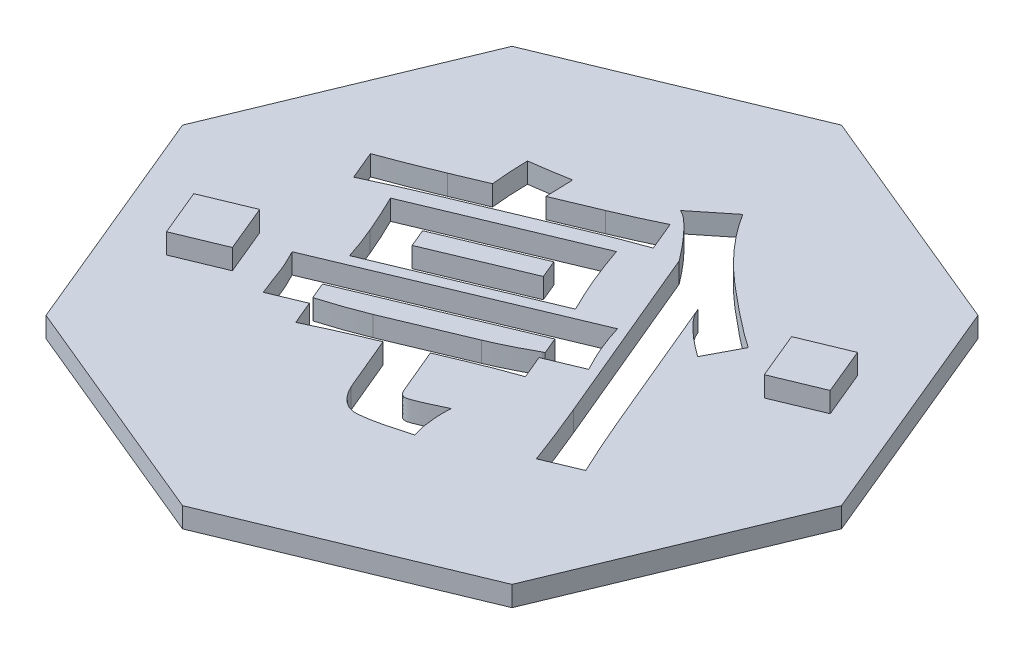
from build123d import *

# Parameters (mm, degrees)
EXTRUDE_1_DEPTH     = 2
CUT_EXTRUDE_1_DEPTH = 2
EXTRUDE_2_DEPTH     = 2
CUT_EXTRUDE_2_DEPTH = 2


with BuildPart() as part:
    # 草图1 → 凸台-拉伸1 (new body)
    with BuildSketch(Plane(origin=(0, 0, 0), x_dir=(1, 0, 0), z_dir=(0, 1, 0))):
        Polygon((32.664074122, 0), (23.096988313, 23.096988313), (0, 32.664074122), (-23.096988313, 23.096988313), (-32.664074122, 0), (-23.096988313, -23.096988313), (0, -32.664074122), (23.096988313, -23.096988313), align=None)
    extrude(amount=EXTRUDE_1_DEPTH)

    # 草图2 → 切除-拉伸1 (cut)
    with BuildSketch(Plane(origin=(0, 0, 0), x_dir=(-1, 0, 0), z_dir=(0, -1, 0))):
        with BuildLine():
            add(Edge.make_bspline(
                [(16.093868601, 4.045594361), (15.797609581, 3.441508397), (15.191422794, 2.205465258), (14.650057175, 0.939674375), (14.37327081, 0.292507942)],
                knots=[0, 0, 0, 0, 0.977451264, 2, 2, 2, 2], degree=3))
            add(Edge.make_bspline(
                [(14.37327081, 0.292507942), (14.251067666, -0.005151179), (14.015944237, -0.577858483), (13.691365396, -1.409985886), (13.414727332, -2.185125978), (13.254412551, -2.685633489), (13.177689264, -2.925165873)],
                knots=[0, 0, 0, 0, 1.124444144, 2.163472675, 3.121076593, 4, 4, 4, 4], degree=3))
            Line((13.177689264, -2.925165873), (-2.614383511, 3.681721717))
            add(Edge.make_bspline(
                [(-2.614383511, 3.681721717), (-2.335416626, 4.24418675), (-1.785453017, 5.353047036), (-1.296073162, 6.489936185), (-1.05492932, 7.050142769)],
                knots=[0, 0, 0, 0, 1.014492161, 2, 2, 2, 2], degree=3))
            add(Edge.make_bspline(
                [(-1.05492932, 7.050142769), (-0.823492736, 7.621996478), (-0.341990134, 8.811735129), (0.081735825, 10.023274771), (0.301795826, 10.652481951)],
                knots=[0, 0, 0, 0, 0.961309795, 2, 2, 2, 2], degree=3))
            Line((0.301795826, 10.652481951), (16.093868601, 4.045594361))
        make_face()
        Polygon((10.952867951, 1.056640495), (11.696207782, 2.834418273), (2.526617139, 6.670675583), (1.783277308, 4.892897805), align=None, mode=Mode.SUBTRACT)
        with BuildLine():
            add(Edge.make_bspline(
                [(0.650073929, 17.352936791), (0.528625853, 17.291965561), (0.258232802, 17.156218682), (-0.145672538, 16.852090468), (-0.602649888, 16.456694691), (-1.103720534, 15.952631829), (-1.659283349, 15.353785572), (-2.26797484, 14.656754371), (-2.922153811, 13.853633684), (-3.367674816, 13.278574375), (-3.602037832, 12.976068695)],
                knots=[0, 0, 0, 0, 0.529975625, 1.179942343, 1.967013512, 2.890804666, 3.954079264, 5.158222661, 6.505104134, 8, 8, 8, 8], degree=3))
            Line((-3.602037832, 12.976068695), (-11.144597936, -5.056419934))
            add(Edge.make_bspline(
                [(-11.144597936, -5.056419934), (-11.560749256, -6.066170811), (-12.386726324, -8.070324178), (-13.147761295, -10.1000242), (-13.525364668, -11.107102195)],
                knots=[0, 0, 0, 0, 1.00765829, 2, 2, 2, 2], degree=3))
            Line((-13.525364668, -11.107102195), (-16.97175843, -9.662007978))
            add(Edge.make_bspline(
                [(-16.97175843, -9.662007978), (-16.515344789, -8.683913243), (-15.618447079, -6.761860855), (-14.789953789, -4.809355654), (-14.383064473, -3.850442026)],
                knots=[0, 0, 0, 0, 1.017760744, 2, 2, 2, 2], degree=3))
            Line((-14.383064473, -3.850442026), (-8.711849398, 9.711611255))
            add(Edge.make_bspline(
                [(-8.711849398, 9.711611255), (-8.768635747, 9.576192979), (-8.891538705, 9.283106576), (-9.178837093, 8.853286544), (-9.548667996, 8.392082955), (-10.013151245, 7.902599454), (-10.562602084, 7.379860625), (-11.206377612, 6.828866385), (-11.939922648, 6.246398661), (-12.468705344, 5.859602102), (-12.745637572, 5.657030359)],
                knots=[0, 0, 0, 0, 0.608207383, 1.316346051, 2.135024255, 3.060935765, 4.113768122, 5.281360114, 6.576203409, 8, 8, 8, 8], degree=3))
            add(Edge.make_bspline(
                [(-12.745637572, 5.657030359), (-12.913552134, 5.979401586), (-13.233274988, 6.593222373), (-13.689379302, 7.462839994), (-14.095129779, 8.237335638), (-14.354865647, 8.717279379), (-14.476631724, 8.942280521)],
                knots=[0, 0, 0, 0, 1.17459343, 2.236520518, 3.173267898, 4, 4, 4, 4], degree=3))
            add(Edge.make_bspline(
                [(-14.476631724, 8.942280521), (-14.300920384, 9.060830104), (-13.928660656, 9.311987686), (-13.351729699, 9.733032157), (-12.713104962, 10.202505378), (-12.02006005, 10.736966006), (-11.268687532, 11.326520979), (-10.46306757, 11.978655629), (-9.598624398, 12.685531184), (-8.693957949, 13.442254995), (-7.778781193, 14.224320346), (-6.910102452, 15.039635825), (-6.08985237, 15.859358557), (-5.315852532, 16.684801699), (-4.605667791, 17.528163283), (-3.945886234, 18.377839109), (-3.324704865, 19.227456213), (-2.957454615, 19.81628166), (-2.775527111, 20.107972529)],
                knots=[0, 0, 0, 0, 0.624797072, 1.323686839, 2.105215423, 2.961352331, 3.903497222, 4.920602144, 6.016748156, 7.195261844, 8.397523628, 9.564826044, 10.706169216, 11.815717331, 12.899427477, 13.954902417, 14.986904706, 16, 16, 16, 16], degree=3))
            Line((-2.775527111, 20.107972529), (0.650073929, 17.352936791))
        make_face()
        with BuildLine():
            add(Edge.make_bspline(
                [(6.986656125, -6.813404989), (7.301317032, -6.939957603), (7.959772221, -7.204779903), (9.005183632, -7.582525656), (10.150941485, -7.959878634), (10.949017228, -8.207737979), (11.363524221, -8.336471915)],
                knots=[0, 0, 0, 0, 0.877828429, 1.83693199, 2.876539196, 4, 4, 4, 4], degree=3))
            Line((11.363524221, -8.336471915), (10.115960868, -11.320227601))
            add(Edge.make_bspline(
                [(10.115960868, -11.320227601), (9.729954805, -11.135724727), (8.990723516, -10.782387539), (7.924823899, -10.289016756), (6.952344225, -9.849119608), (6.330415569, -9.584708546), (6.035389069, -9.459278933)],
                knots=[0, 0, 0, 0, 1.14461078, 2.192017644, 3.142341002, 4, 4, 4, 4], degree=3))
            Line((6.035389069, -9.459278933), (4.127656775, -8.658759115))
            Line((4.127656775, -8.658759115), (1.845655475, -14.111650603))
            add(Edge.make_bspline(
                [(1.845655475, -14.111650603), (1.755644329, -14.283543624), (1.583517145, -14.612252489), (1.280105734, -15.051731058), (0.959924509, -15.419999049), (0.616323836, -15.709665903), (0.259846681, -15.937396895), (-0.124946041, -16.078941435), (-0.527616305, -16.140417879), (-0.948021685, -16.131838856), (-1.388036152, -16.063565293), (-1.864272592, -15.995868595), (-2.373000907, -15.893260528), (-2.919005882, -15.774262108), (-3.501153746, -15.633120366), (-4.118232955, -15.472481361), (-4.769611799, -15.289704958), (-5.213664503, -15.157134974), (-5.442193777, -15.088908563)],
                knots=[0, 0, 0, 0, 1.12099087, 2.143656759, 3.080474238, 3.933513291, 4.734236404, 5.514002854, 6.28483668, 7.076356498, 7.935024684, 8.857428312, 9.857517109, 10.934394087, 12.088603092, 13.32058556, 14.621054139, 16, 16, 16, 16], degree=3))
            add(Edge.make_bspline(
                [(-5.442193777, -15.088908563), (-5.351871048, -14.776892277), (-5.168766904, -14.144366272), (-5.023450603, -13.145778745), (-4.943018512, -12.099305758), (-4.970629008, -11.384440946), (-4.984753881, -11.018733124)],
                knots=[0, 0, 0, 0, 0.945578486, 1.916896679, 2.934333924, 4, 4, 4, 4], degree=3))
            add(Edge.make_bspline(
                [(-4.984753881, -11.018733124), (-4.790847683, -11.110907326), (-4.42260794, -11.285951777), (-3.898581085, -11.528685049), (-3.433739183, -11.744604284), (-3.026727982, -11.925384347), (-2.6751308, -12.073315457), (-2.381740422, -12.186560583), (-2.146333985, -12.270874943), (-1.921608575, -12.343644017), (-1.681251188, -12.363075023), (-1.426685911, -12.279098104), (-1.217234804, -12.094046724), (-1.135377032, -11.922165451), (-1.091316584, -11.829649303)],
                knots=[0, 0, 0, 0, 1.75727236, 3.337167794, 4.726874983, 5.952299164, 6.982142917, 7.848648666, 8.525986127, 9.028603242, 9.781461031, 10.454180059, 11.167952948, 12, 12, 12, 12], degree=3))
            Line((-1.091316584, -11.829649303), (0.816415709, -7.276043066))
            Line((0.816415709, -7.276043066), (-1.813863693, -6.174028771))
            add(Edge.make_bspline(
                [(-1.813863693, -6.174028771), (-2.13587428, -6.041669541), (-2.790307403, -5.772671353), (-3.796809741, -5.373853668), (-4.849321953, -4.988445414), (-5.566741733, -4.733539559), (-5.930822757, -4.604178218)],
                knots=[0, 0, 0, 0, 0.948046538, 1.926747385, 2.947851791, 4, 4, 4, 4], degree=3))
            Line((-5.930822757, -4.604178218), (-4.683259404, -1.620422533))
            add(Edge.make_bspline(
                [(-4.683259404, -1.620422533), (-4.338036667, -1.813500775), (-3.656638491, -2.194597232), (-2.625617228, -2.715586575), (-1.614318872, -3.203477177), (-0.936462835, -3.494176659), (-0.602687605, -3.63731662)],
                knots=[0, 0, 0, 0, 1.042091168, 2.056872116, 3.043206934, 4, 4, 4, 4], degree=3))
            Line((-0.602687605, -3.63731662), (6.986656125, -6.813404989))
        make_face()
        with BuildLine():
            add(Edge.make_bspline(
                [(16.358975813, -5.43588712), (16.242836134, -5.656792271), (16.015225652, -6.08972207), (15.709843027, -6.743111047), (15.430403129, -7.378326322), (15.13058927, -8.204912883), (14.770924016, -9.196992014), (14.458702726, -9.969560292), (14.305694462, -10.348167822)],
                knots=[0, 0, 0, 0, 0.842857433, 1.65183156, 2.435688405, 3.185759508, 4.6208434, 6, 6, 6, 6], degree=3))
            Line((14.305694462, -10.348167822), (11.119209731, -9.017433579))
            Line((11.119209731, -9.017433579), (12.08607133, -6.704243196))
            Line((12.08607133, -6.704243196), (-4.15304498, 0.094977077))
            Line((-4.15304498, 0.094977077), (-5.119906578, -2.218213306))
            Line((-5.119906578, -2.218213306), (-8.436345824, -0.835497257))
            add(Edge.make_bspline(
                [(-8.436345824, -0.835497257), (-8.314627446, -0.598333908), (-8.082516959, -0.146075991), (-7.759338065, 0.49995068), (-7.486607848, 1.086373847), (-7.326603731, 1.458281441), (-7.251160639, 1.633638546)],
                knots=[0, 0, 0, 0, 1.167656215, 2.226658417, 3.163856695, 4, 4, 4, 4], degree=3))
            add(Edge.make_bspline(
                [(-7.251160639, 1.633638546), (-7.097580529, 2.02014236), (-6.778226528, 2.823837183), (-6.518095982, 3.648637011), (-6.383064473, 4.076783445)],
                knots=[0, 0, 0, 0, 0.961817353, 2, 2, 2, 2], degree=3))
            Line((-6.383064473, 4.076783445), (16.358975813, -5.43588712))
        make_face()
        with BuildLine():
            add(Edge.make_bspline(
                [(12.486331239, 14.020903003), (12.478695551, 13.69165781), (12.463781285, 13.048565689), (12.42463406, 12.10540087), (12.357267249, 11.20575478), (12.293820878, 10.621141189), (12.262809471, 10.335392932)],
                knots=[0, 0, 0, 0, 1.069883436, 2.089730157, 3.066295606, 4, 4, 4, 4], degree=3))
            Line((12.262809471, 10.335392932), (15.423303299, 9.009856869))
            add(Edge.make_bspline(
                [(15.423303299, 9.009856869), (15.913396476, 8.808210949), (16.869463055, 8.414843048), (18.270747575, 7.850970888), (19.608573249, 7.342579524), (20.4791056, 7.02335168), (20.90218569, 6.868206447)],
                knots=[0, 0, 0, 0, 1.080965888, 2.10873239, 3.080840972, 4, 4, 4, 4], degree=3))
            Line((20.90218569, 6.868206447), (19.711802324, 4.014405277))
            add(Edge.make_bspline(
                [(19.711802324, 4.014405277), (18.822004235, 4.432515769), (17.045637292, 5.267219356), (15.238706529, 6.033513952), (14.336883546, 6.415964732)],
                knots=[0, 0, 0, 0, 1.001817887, 2, 2, 2, 2], degree=3))
            Line((14.336883546, 6.415964732), (3.27515515, 11.047543679))
            add(Edge.make_bspline(
                [(3.27515515, 11.047543679), (2.929136533, 11.190936111), (2.222237029, 11.483879999), (1.123725329, 11.909671499), (-0.030118119, 12.345181739), (-0.822404842, 12.632172958), (-1.226469281, 12.778537831)],
                knots=[0, 0, 0, 0, 0.931797729, 1.90361824, 2.93085004, 4, 4, 4, 4], degree=3))
            Line((-1.226469281, 12.778537831), (-0.036085915, 15.632339001))
            add(Edge.make_bspline(
                [(-0.036085915, 15.632339001), (0.696257069, 15.282370936), (2.148422597, 14.588418006), (3.628110045, 13.955276918), (4.361574904, 13.641435817)],
                knots=[0, 0, 0, 0, 1.00862191, 2, 2, 2, 2], degree=3))
            Line((4.361574904, 13.641435817), (8.530515774, 11.894847123))
            add(Edge.make_bspline(
                [(8.530515774, 11.894847123), (8.537587927, 12.090640434), (8.552482363, 12.502994494), (8.572988056, 13.152779971), (8.593917286, 13.866661865), (8.606900987, 14.363978916), (8.613686664, 14.623891957)],
                knots=[0, 0, 0, 0, 0.861087373, 1.813508701, 2.857273038, 4, 4, 4, 4], degree=3))
            add(Edge.make_bspline(
                [(8.613686664, 14.623891957), (8.899450329, 14.572847931), (9.494525346, 14.466553714), (10.426963286, 14.31664977), (11.432104069, 14.166585619), (12.12756101, 14.070481108), (12.486331239, 14.020903003)],
                knots=[0, 0, 0, 0, 0.888701254, 1.850633858, 2.891191479, 4, 4, 4, 4], degree=3))
        make_face()
    extrude(amount=-CUT_EXTRUDE_1_DEPTH, mode=Mode.SUBTRACT)


with BuildPart() as cut_extrude_1_piece_1:
    # of the separate pieces the step leaves, piece 1, a body of its own (cut_extrude_1_pieces)
    add(part.part.solids().sort_by_distance((32.664074122, 0, 0))[0])

    # 草图4 → 凸台-拉伸2 (add)
    with BuildSketch(Plane(origin=(0, 2, 0), x_dir=(1, 0, 0), z_dir=(0, 1, 0))):
        Polygon((-24.217842136, -7.325378163), (-22.304424974, -11.944775826), (-17.685027311, -10.031358664), (-19.598444473, -5.411961001), align=None)
        Polygon((19.598444473, 5.411961001), (17.685027311, 10.031358664), (22.304424974, 11.944775826), (24.217842136, 7.325378163), align=None)
    extrude(amount=EXTRUDE_2_DEPTH)

    # 草图5 → 切除-拉伸2 (cut)
    with BuildSketch(Plane(origin=(0, 0, 0), x_dir=(-1, 0, 0), z_dir=(0, -1, 0))):
        Polygon((-4.683259404, -1.620422533), (-4.9959692, -1.489716865), (-5.273074657, -2.154353261), (-4.96105409, -2.284814822), align=None)
        Polygon((11.363524221, -8.336471915), (11.740494099, -8.494089983), (11.462129349, -9.160643077), (11.084875677, -9.00290635), align=None)
    extrude(amount=-CUT_EXTRUDE_2_DEPTH, mode=Mode.SUBTRACT)


with BuildPart() as cut_extrude_1_piece_2:
    # of the separate pieces the step leaves, piece 2, a body of its own (cut_extrude_1_pieces)
    add(part.part.solids().sort_by_distance((-10.952867951, 0, -1.056640495))[0])


with BuildPart() as cut_extrude_2_piece_1:
    # of the separate pieces the step leaves, piece 1, a body of its own (cut_extrude_2_pieces)
    add(cut_extrude_1_piece_1.part.solids().sort_by_distance((32.664074122, 0, 0))[0])


with BuildPart() as cut_extrude_2_piece_2:
    # of the separate pieces the step leaves, piece 2, a body of its own (cut_extrude_2_pieces)
    add(cut_extrude_1_piece_1.part.solids().sort_by_distance((-6.986656125, 0, 6.813404989))[0])


solid = Compound([cut_extrude_1_piece_2.part, cut_extrude_2_piece_1.part, cut_extrude_2_piece_2.part])
